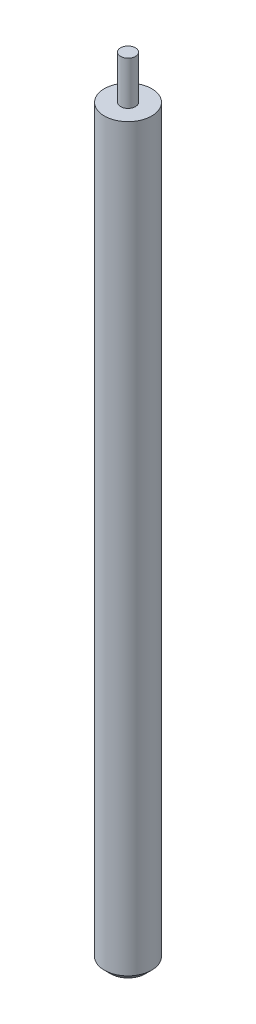
from build123d import *

# Parameters (mm, degrees)
CHANFRO1_SIZE = 5


with BuildPart() as part:
    # Esboço1 → Revolução1 (revolve)
    with BuildSketch(Plane.XY):
        Polygon((0, 635), (6, 635), (6, 600), (19.05, 600), (19.05, 0), (0, 0), align=None)
    revolve(axis=Axis((0, 0, 0), (0, 1, 0)))

    # Chanfro1
    chanfro1_edges = [part.edges().sort_by_distance(p)[0] for p in [
        (-19.05, 0, 0),
    ]]
    chamfer(chanfro1_edges, length=CHANFRO1_SIZE)


solid = part.part
